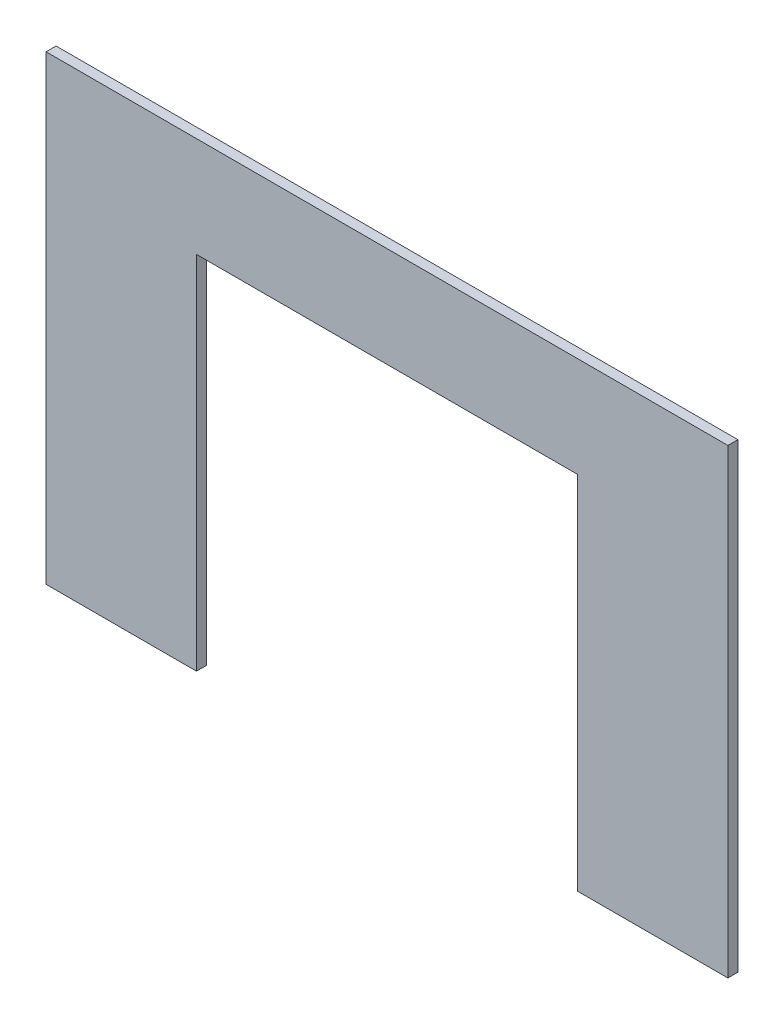
from build123d import *

# Parameters (mm, degrees)
BOSS_EXTRUDE1_DEPTH = 6.35


with BuildPart() as part:
    # Sketch1 → Boss-Extrude1 (new body)
    with BuildSketch(Plane.XY):
        Polygon((0, 12.7), (0, 304.8), (431.8, 304.8), (431.8, 12.7), (336.55, 12.7), (336.55, 241.3), (95.25, 241.3), (95.25, 12.7), align=None)
    extrude(amount=BOSS_EXTRUDE1_DEPTH)


solid = part.part
